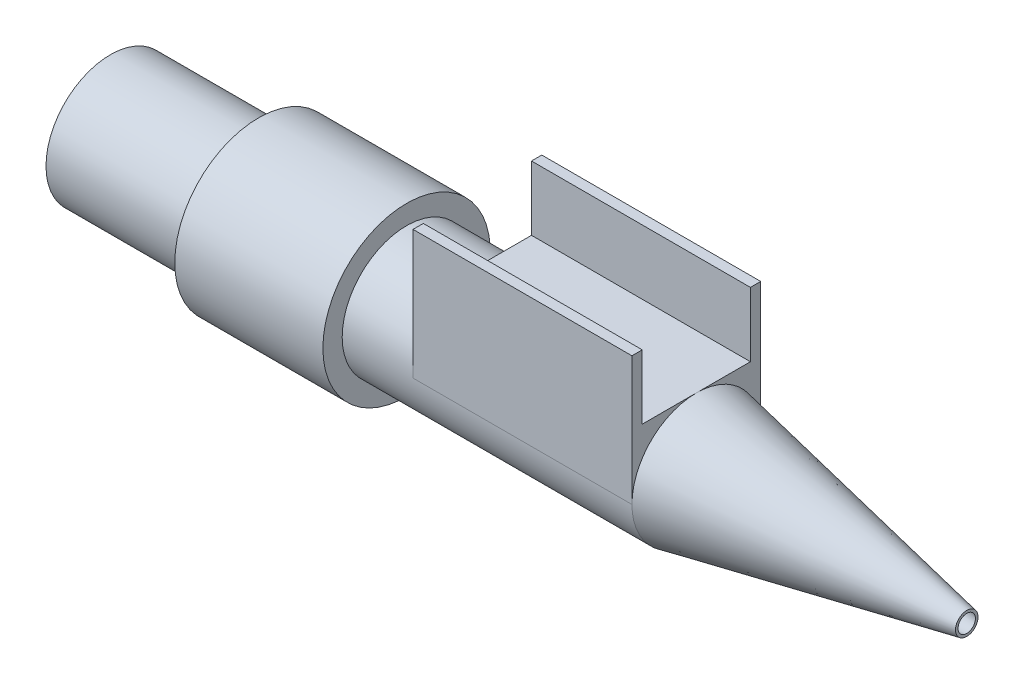
from build123d import *

# Parameters (mm, degrees)
SKICA2_W                = 17
SKICA2_H                = 10
P_IDAT_VYSUNUT_M1_DEPTH = 5
SKICA3_W                = 17
SKICA3_H                = 0.8
P_IDAT_VYSUNUT_M2_DEPTH = 5


with BuildPart() as part:
    # Skica1 → Rotovat1 (revolve)
    with BuildSketch(Plane.XY):
        Polygon((0, 0), (0, 5), (11.5, 5), (11.5, 6.5), (23, 6.5), (23, 5), (45.5, 5), (66.5, 0.875), (66.5, 0), align=None)
    revolve(axis=Axis((0, 0, 0), (1, 0, 0)))

    # Skica2 → Přidat vysunutím1 (add)
    with BuildSketch(Plane(origin=(0, 0, 0), x_dir=(1, 0, 0), z_dir=(0, 1, 0))):
        with Locations((37, 0)):
            Rectangle(SKICA2_W, SKICA2_H)
    extrude(amount=P_IDAT_VYSUNUT_M1_DEPTH)

    # Skica3 → Přidat vysunutím2 (add)
    with BuildSketch(Plane(origin=(0, 5, 0), x_dir=(1, 0, 0), z_dir=(0, 1, 0))):
        with Locations((37, -4.6)):
            Rectangle(SKICA3_W, SKICA3_H)
        with Locations((37, 4.6)):
            Rectangle(SKICA3_W, SKICA3_H)
    extrude(amount=P_IDAT_VYSUNUT_M2_DEPTH)

    # Skica4 → Odebrat rotací1 (revolve, cut)
    with BuildSketch(Plane.XY):
        Polygon((0, 0), (0, 3.5), (45.5, 3.5), (66.5, 0.675), (66.5, 0), align=None)
    revolve(axis=Axis((0, 0, 0), (1, 0, 0)), mode=Mode.SUBTRACT)


solid = part.part
